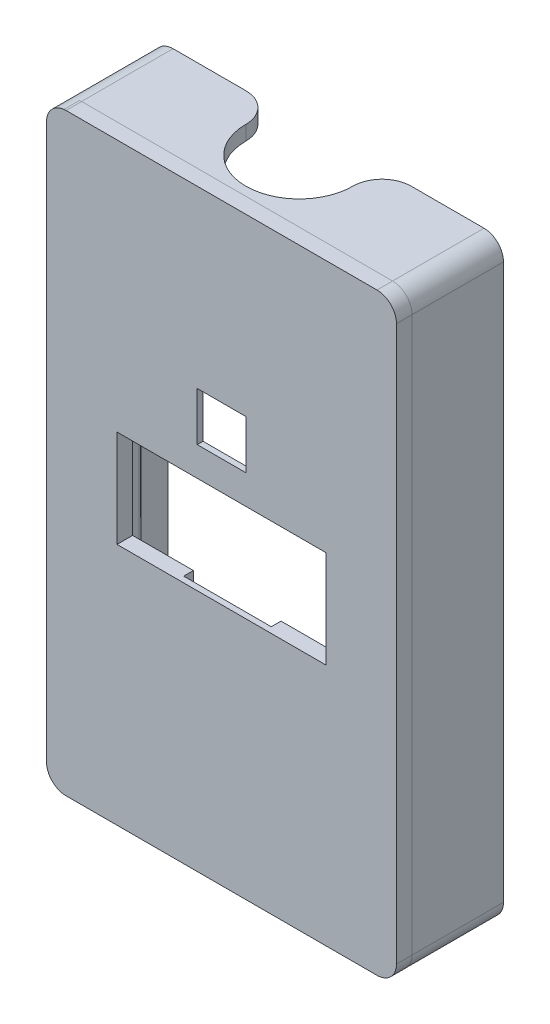
from build123d import *

# Parameters (mm, degrees)
SKETCH_1_R          = 0.7
EXTRUDE_1_DEPTH     = 11
SKETCH_3_W          = 21.5
SKETCH_3_H          = 10
EXTRUDE_2_DEPTH     = 1.6
SKETCH_4_W          = 5
SKETCH_4_H          = 5
CUT_EXTRUDE_1_DEPTH = 1
CUT_EXTRUDE_2_REACH = 62.995
SKETCH_5_R          = 1.5
SKETCH_5_W          = 8
SKETCH_5_H          = 3
SKETCH_6_W          = 9.004768993
SKETCH_6_H          = 22
SKETCH_6_H_2        = 21.052305639
CUT_EXTRUDE_3_DEPTH = 1
SKETCH_7_W          = 5.5
SKETCH_7_H          = 20
SKETCH_7_W_2        = 4.9
SKETCH_7_W_3        = 2
SKETCH_7_H_2        = 2
EXTRUDE_4_DEPTH     = 2
FILLET_2_R          = 0.5
CUT_EXTRUDE_4_REACH = 62.994
SKETCH_9_R          = 5.5
FILLET_3_R          = 3


with BuildPart() as part:
    # Эскиз1 → Бобышка-Вытянуть1 (new body)
    with BuildSketch(Plane.XY):
        with BuildLine():
            Line((-15.979444254, 30.494289473), (15.979444254, 30.494289473))
            ThreePointArc((15.979444254, 30.494289473), (17.393657817, 29.908503035), (17.979444254, 28.494289473))
            Line((17.979444254, 28.494289473), (17.979444254, -28.500000343))
            ThreePointArc((17.979444254, -28.500000343), (17.393657817, -29.914213905), (15.979444254, -30.500000343))
            Line((15.979444254, -30.500000343), (-15.979444254, -30.500000343))
            ThreePointArc((-15.979444254, -30.500000343), (-17.393657817, -29.914213905), (-17.979444254, -28.500000343))
            Line((-17.979444254, -28.500000343), (-17.979444254, 28.494289473))
            ThreePointArc((-17.979444254, 28.494289473), (-17.393657817, 29.908503035), (-15.979444254, 30.494289473))
        make_face()
        with Locations((-15.979444254, 28.500000343)):
            Circle(SKETCH_1_R, mode=Mode.SUBTRACT)
        with Locations((16.01925313, 28.489204167)):
            Circle(SKETCH_1_R, mode=Mode.SUBTRACT)
        with Locations((16.028296267, -28.484120661)):
            Circle(SKETCH_1_R, mode=Mode.SUBTRACT)
        with Locations((-15.970396078, -28.505074873)):
            Circle(SKETCH_1_R, mode=Mode.SUBTRACT)
        with BuildLine():
            Line((-14.027975552, -29.00000033), (14.122849497, -29.00000033))
            ThreePointArc((14.122849497, -29.00000033), (14.623833191, -27.096913866), (16.520580958, -26.572442078))
            Line((16.520580958, -26.572442078), (16.520580958, 26.576499963))
            ThreePointArc((16.520580958, 26.576499963), (14.617623044, 27.094499874), (14.109055694, 29.00000033))
            Line((14.109055694, 29.00000033), (-14.044436107, 29.00000033))
            ThreePointArc((-14.044436107, 29.00000033), (-14.570671317, 27.074656136), (-16.499999911, 26.563221942))
            Line((-16.499999911, 26.563221942), (-16.499999911, -26.57182153))
            ThreePointArc((-16.499999911, -26.57182153), (-14.565751702, -27.075066872), (-14.027975552, -29.00000033))
        make_face(mode=Mode.SUBTRACT)
    extrude(amount=EXTRUDE_1_DEPTH)

    # Эскиз3 → Бобышка-Вытянуть2 (add)
    with BuildSketch(Plane.XY.offset(11)):
        with BuildLine():
            Line((-17.973934657, 28.494881466), (-17.973934657, -28.49940835))
            ThreePointArc((-17.973934657, -28.49940835), (-17.388148219, -29.913621912), (-15.973934657, -30.49940835))
            Line((-15.973934657, -30.49940835), (15.984953852, -30.49940835))
            ThreePointArc((15.984953852, -30.49940835), (17.399167415, -29.913621912), (17.984953852, -28.49940835))
            Line((17.984953852, -28.49940835), (17.984953852, 28.494881466))
            ThreePointArc((17.984953852, 28.494881466), (17.399167415, 29.909095028), (15.984953852, 30.494881466))
            Line((15.984953852, 30.494881466), (-15.973934657, 30.494881466))
            ThreePointArc((-15.973934657, 30.494881466), (-17.388148219, 29.909095028), (-17.973934657, 28.494881466))
        make_face()
        with Locations((0.015800122, -0.505118534)):
            Rectangle(SKETCH_3_W, SKETCH_3_H, mode=Mode.SUBTRACT)
    extrude(amount=-EXTRUDE_2_DEPTH)

    # Эскиз4 → Вырез-Вытянуть1 (cut)
    with BuildSketch(Plane.XY.offset(11)):
        with Locations((0.003657856, 9.994881549)):
            Rectangle(SKETCH_4_W, SKETCH_4_H)
    extrude(amount=-CUT_EXTRUDE_1_DEPTH, mode=Mode.SUBTRACT)

    # Эскиз5 → Вырез-Вытянуть2 (cut, up to next)
    with BuildSketch(Plane.XZ.offset(30.500000343), mode=Mode.PRIVATE) as cut_extrude_2_sk1:
        with Locations((-10.979444254, 2.5)):
            Circle(SKETCH_5_R)
    cut_extrude_2_tool1 = extrude(cut_extrude_2_sk1.sketch, amount=-CUT_EXTRUDE_2_REACH, mode=Mode.PRIVATE) & part.part
    add(cut_extrude_2_tool1.solids().sort_by_distance((-10.979444, -30.5, 2.5))[0], mode=Mode.SUBTRACT)
    # Эскиз5 → Вырез-Вытянуть2 (cut, up to next)
    with BuildSketch(Plane.XZ.offset(30.500000343), mode=Mode.PRIVATE) as cut_extrude_2_sk2:
        with Locations((7.979444254, 2.5)):
            Rectangle(SKETCH_5_W, SKETCH_5_H)
    cut_extrude_2_tool2 = extrude(cut_extrude_2_sk2.sketch, amount=-CUT_EXTRUDE_2_REACH, mode=Mode.PRIVATE) & part.part
    add(cut_extrude_2_tool2.solids().sort_by_distance((7.979444, -30.5, 2.5))[0], mode=Mode.SUBTRACT)

    # Эскиз6 → Вырез-Вытянуть3 (cut)
    with BuildSketch(Plane(origin=(0, 0, 9.4), x_dir=(-1, 0, 0), z_dir=(0, 0, -1))):
        with Locations((-0.015800121, 15.494881466)):
            Rectangle(SKETCH_6_W, SKETCH_6_H)
        with Locations((-0.015800121, -16.031271353)):
            Rectangle(SKETCH_6_W, SKETCH_6_H_2)
    extrude(amount=-CUT_EXTRUDE_3_DEPTH, mode=Mode.SUBTRACT)

    # Эскиз7 → Бобышка-Вытянуть4 (add)
    with BuildSketch(Plane(origin=(0, 0, 9.4), x_dir=(-1, 0, 0), z_dir=(0, 0, -1))):
        with Locations((-13.770580958, 3.3e-07)):
            Rectangle(SKETCH_7_W, SKETCH_7_H)
        with Locations((14.049999911, 3.3e-07)):
            Rectangle(SKETCH_7_W_2, SKETCH_7_H)
        with Locations((-5.520580958, 16.00000033)):
            Rectangle(SKETCH_7_W_3, SKETCH_7_H_2)
        Polygon((6.48268437, 17.014487668), (6.487140887, 15.014492633), (4.487145853, 15.010036116), (4.482689335, 17.01003115), align=None)
    extrude(amount=EXTRUDE_4_DEPTH)

    # Скругление2
    fillet_2_edges = [part.edges().sort_by_distance(p)[0] for p in [
        (16.520580958, 10.00000033, 8.4),
        (13.770580958, -9.99999967, 9.4),
        (16.520580958, -9.99999967, 8.4),
        (13.770580958, 10.00000033, 9.4),
        (16.520580958, 3.3e-07, 7.4),
        (11.020580958, 3.3e-07, 7.4),
        (-16.499999911, -9.99999967, 8.4),
        (-14.049999911, 10.00000033, 9.4),
        (-16.499999911, 10.00000033, 8.4),
        (-14.049999911, -9.99999967, 9.4),
        (-16.499999911, 3.3e-07, 7.4),
        (-11.599999911, 3.3e-07, 7.4),
        (6.520580958, 16.00000033, 9.4),
        (5.520580958, 17.00000033, 9.4),
        (5.520580958, 15.00000033, 7.4),
        (5.520580958, 17.00000033, 7.4),
        (-5.484634372, 17.012263749, 9.4),
        (-6.484912629, 16.014490151, 9.4),
        (-5.48714337, 15.012264374, 7.4),
    ]]
    fillet(fillet_2_edges, radius=FILLET_2_R)

    # Эскиз9 → Вырез-Вытянуть4 (cut, up to next)
    with BuildSketch(Plane(origin=(0, 30.494289473, 0), x_dir=(1, 0, 0), z_dir=(0, 1, 0)), mode=Mode.PRIVATE) as cut_extrude_4_sk1:
        with Locations((0, -3)):
            Circle(SKETCH_9_R)
    cut_extrude_4_tool1 = extrude(cut_extrude_4_sk1.sketch, amount=-CUT_EXTRUDE_4_REACH, mode=Mode.PRIVATE) & part.part
    add(cut_extrude_4_tool1.solids().sort_by_distance((0, 30.494289, 3))[0], mode=Mode.SUBTRACT)

    # Скругление3
    fillet_3_edges = [part.edges().sort_by_distance(p)[0] for p in [
        (4.609772229, 29.747144901, 0),
        (-4.609772229, 29.747144901, 0),
    ]]
    fillet(fillet_3_edges, radius=FILLET_3_R)


solid = part.part
